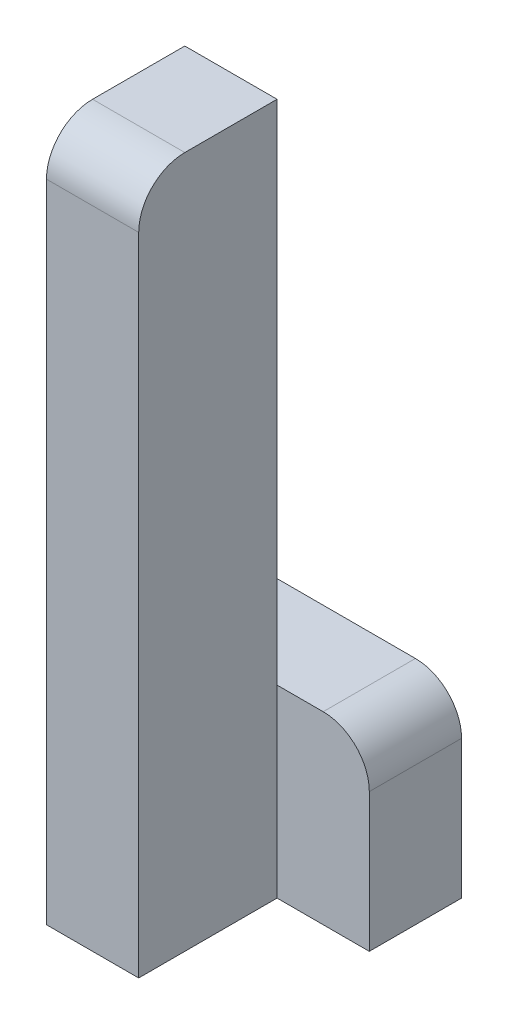
from build123d import *

# Parameters (mm, degrees)
SKETCH1_W           = 20
SKETCH1_H           = 150
BOSS_EXTRUDE1_DEPTH = 30
SKETCH2_W           = 40
SKETCH2_H           = 40
BOSS_EXTRUDE2_DEPTH = 20
FILLET1_R           = 10


with BuildPart() as part:
    # Sketch1 → Boss-Extrude1 (new body)
    with BuildSketch(Plane.XY):
        with Locations((-20, -75)):
            Rectangle(SKETCH1_W, SKETCH1_H)
    extrude(amount=BOSS_EXTRUDE1_DEPTH)

    # Sketch2 → Boss-Extrude2 (add)
    with BuildSketch(Plane.XY):
        with Locations((-10, -130)):
            Rectangle(SKETCH2_W, SKETCH2_H)
    extrude(amount=-BOSS_EXTRUDE2_DEPTH)

    # Fillet1
    fillet1_edges = [part.edges().sort_by_distance(p)[0] for p in [
        (10, -110, -10),
        (-20, 0, 30),
    ]]
    fillet(fillet1_edges, radius=FILLET1_R)


solid = part.part
